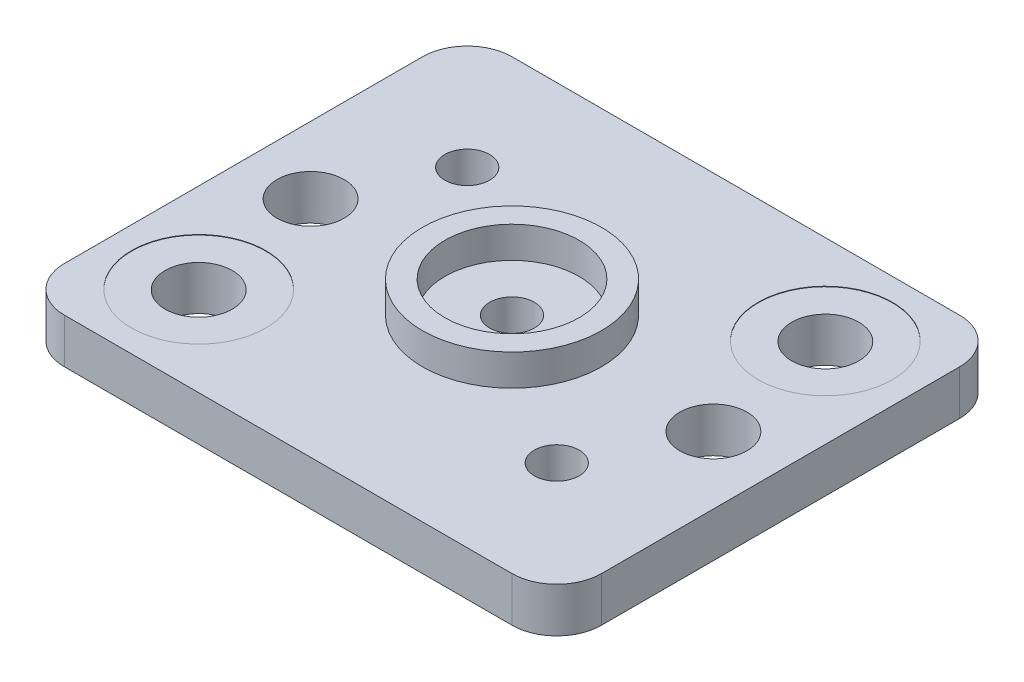
from build123d import *

# Parameters (mm, degrees)
SALIENTE_EXTRUIR1_DEPTH = 1
REDONDEO1_R             = 1
CROQUIS2_R              = 1.5
CORTAR_EXTRUIR3_DEPTH   = 0.01
CROQUIS5_R              = 0.75
CORTAR_EXTRUIR5_DEPTH   = 1.1
CROQUIS6_R              = 0.75
CROQUIS6_R_2            = 0.5
CORTAR_EXTRUIR6_DEPTH   = 1.1
CROQUIS7_R              = 2
SALIENTE_EXTRUIR2_DEPTH = 0.7
CROQUIS8_R              = 1.5
CORTAR_EXTRUIR7_DEPTH   = 0.7
CROQUIS9_R              = 0.5
CORTAR_EXTRUIR9_DEPTH   = 8


with BuildPart() as part:
    # Croquis1 → Saliente-Extruir1 (new body)
    with BuildSketch(Plane(origin=(0, 0, 0), x_dir=(1, 0, 0), z_dir=(0, 1, 0))):
        Polygon((-6, 5), (6, 5), (6, 0.5), (6, -5), (1.5, -5), (-6, -5), align=None)
    extrude(amount=SALIENTE_EXTRUIR1_DEPTH)

    # Redondeo1
    redondeo1_edges = [part.edges().sort_by_distance(p)[0] for p in [
        (-6, 0.5, -5),
        (6, 0.5, -5),
        (6, 0.5, 5),
        (-6, 0.5, 5),
    ]]
    fillet(redondeo1_edges, radius=REDONDEO1_R)

    # Croquis2 → Cortar-Extruir3 (cut)
    with BuildSketch(Plane(origin=(0, 1, 0), x_dir=(1, 0, 0), z_dir=(0, 1, 0))):
        with Locations((4, 3)):
            Circle(CROQUIS2_R)
        with Locations((-4, -3)):
            Circle(CROQUIS2_R)
    extrude(amount=-CORTAR_EXTRUIR3_DEPTH, mode=Mode.SUBTRACT)

    # Croquis5 → Cortar-Extruir5 (cut)
    with BuildSketch(Plane(origin=(0, 0.99, 0), x_dir=(1, 0, 0), z_dir=(0, 1, 0))):
        with Locations((4, 3)):
            Circle(CROQUIS5_R)
        with Locations((-4, -3)):
            Circle(CROQUIS5_R)
    extrude(amount=-CORTAR_EXTRUIR5_DEPTH, mode=Mode.SUBTRACT)

    # Croquis6 → Cortar-Extruir6 (cut)
    with BuildSketch(Plane(origin=(0, 1, 0), x_dir=(1, 0, 0), z_dir=(0, 1, 0))):
        with Locations((4.5, 0)):
            Circle(CROQUIS6_R)
        with Locations((-4.5, 0)):
            Circle(CROQUIS6_R)
        with Locations((3.36, -2.36)):
            Circle(CROQUIS6_R_2)
        with Locations((-3.36, 2.36)):
            Circle(CROQUIS6_R_2)
    extrude(amount=-CORTAR_EXTRUIR6_DEPTH, mode=Mode.SUBTRACT)

    # Croquis7 → Saliente-Extruir2 (add)
    with BuildSketch(Plane(origin=(0, 1, 0), x_dir=(1, 0, 0), z_dir=(0, 1, 0))):
        Circle(CROQUIS7_R)
    extrude(amount=SALIENTE_EXTRUIR2_DEPTH)

    # Croquis8 → Cortar-Extruir7 (cut)
    with BuildSketch(Plane(origin=(0, 1.7, 0), x_dir=(1, 0, 0), z_dir=(0, 1, 0))):
        Circle(CROQUIS8_R)
    extrude(amount=-CORTAR_EXTRUIR7_DEPTH, mode=Mode.SUBTRACT)

    # Croquis9 → Cortar-Extruir9 (cut)
    with BuildSketch(Plane(origin=(0, 1, 0), x_dir=(1, 0, 0), z_dir=(0, 1, 0))):
        Circle(CROQUIS9_R)
    extrude(amount=-CORTAR_EXTRUIR9_DEPTH, mode=Mode.SUBTRACT)


solid = part.part
